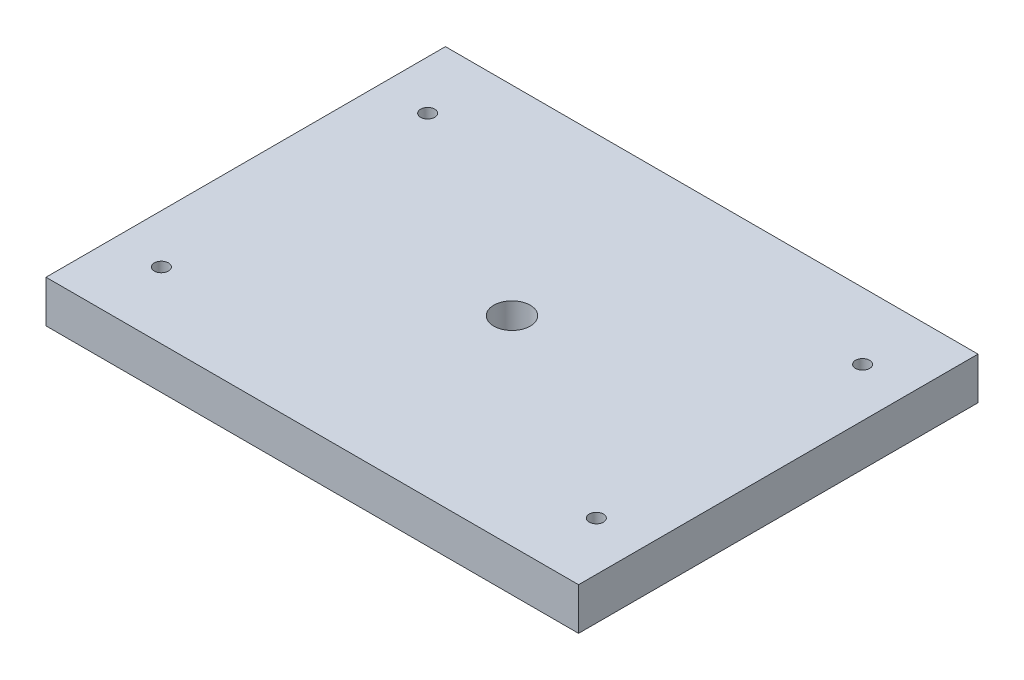
from build123d import *

# Parameters (mm, degrees)
SKETCH1_W           = 120
SKETCH1_H           = 90
BOSS_EXTRUDE1_DEPTH = 9.5
SKETCH2_R           = 1.6
CUT_EXTRUDE1_DEPTH  = 10.5
SKETCH3_R           = 4.1
CUT_EXTRUDE2_DEPTH  = 10.5


with BuildPart() as part:
    # Sketch1 → Boss-Extrude1 (new body)
    with BuildSketch(Plane(origin=(0, 0, 0), x_dir=(1, 0, 0), z_dir=(0, 1, 0))):
        Rectangle(SKETCH1_W, SKETCH1_H)
    extrude(amount=BOSS_EXTRUDE1_DEPTH)

    # Sketch2 → Cut-Extrude1 (cut, through all)
    with BuildSketch(Plane(origin=(0, 9.5, 0), x_dir=(1, 0, 0), z_dir=(0, 1, 0))):
        with Locations((-49, -30)):
            Circle(SKETCH2_R)
        with Locations((49, -30)):
            Circle(SKETCH2_R)
        with Locations((49, 30)):
            Circle(SKETCH2_R)
        with Locations((-49, 30)):
            Circle(SKETCH2_R)
    extrude(amount=-CUT_EXTRUDE1_DEPTH, mode=Mode.SUBTRACT)

    # Sketch3 → Cut-Extrude2 (cut, through all)
    with BuildSketch(Plane(origin=(0, 9.5, 0), x_dir=(1, 0, 0), z_dir=(0, 1, 0))):
        Circle(SKETCH3_R)
    extrude(amount=-CUT_EXTRUDE2_DEPTH, mode=Mode.SUBTRACT)


solid = part.part
